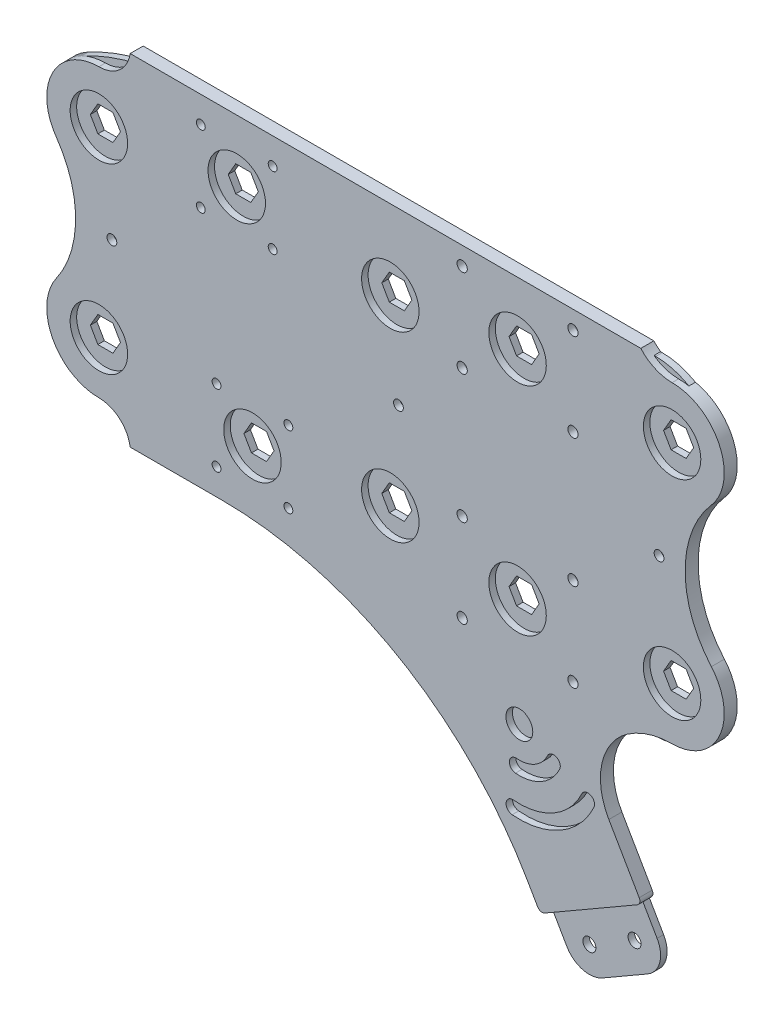
from build123d import *

# Parameters (mm, degrees)
SKETCH1_R           = 2.159
SKETCH1_R_2         = 2.5
SKETCH1_R_3         = 3.175
BOSS_EXTRUDE3_DEPTH = 3.175
SKETCH4_R           = 14
SKETCH4_R_2         = 2.38125
SKETCH4_R_3         = 2.159
SKETCH4_R_4         = 2.5
SKETCH4_R_5         = 6.54812
BOSS_EXTRUDE4_DEPTH = 6.35
FILLET1_R           = 2.54


with BuildPart() as part:
    # Sketch1 → Boss-Extrude3 (new body)
    with BuildSketch(Plane.XY):
        with BuildLine():
            Line((113.584291992, 80.1116), (113.584291992, 54.7116))
            Line((113.584291992, 54.7116), (88.184291992, 54.7116))
            Line((88.184291992, 54.7116), (88.184291992, 80.1116))
            Line((88.184291992, 80.1116), (39.822691992, 80.1116))
            ThreePointArc((39.822691992, 80.1116), (12.922826287, 76.701489547), (-12.275183404, 66.686903391))
            ThreePointArc((-12.275183404, 66.686903391), (-25.397490808, 44.807016355), (-12.895384615, 22.566923077))
            ThreePointArc((-12.895384615, 22.566923077), (0, 0), (-12.895384615, -22.566923077))
            ThreePointArc((-12.895384615, -22.566923077), (-25.397490808, -44.807016355), (-12.275183404, -66.686903391))
            ThreePointArc((-12.275183404, -66.686903391), (7.438885646, -75.132543085), (28.434721687, -79.50841069))
            Line((28.434721687, -79.50841069), (28.434721687, -54.7116))
            Line((28.434721687, -54.7116), (53.834721687, -54.7116))
            Line((53.834721687, -54.7116), (53.834721687, -80.1116))
            Line((53.834721687, -80.1116), (131.769044239, -80.1116))
            ThreePointArc((131.769044239, -80.1116), (157.169044239, -86.917509488), (175.763134751, -105.5116))
            Line((175.763134751, -105.5116), (224.861657379, -190.552735768))
            ThreePointArc((224.861657379, -190.552735768), (232.573178135, -196.469993762), (242.210180007, -195.201258396))
            Line((242.210180007, -195.201258396), (264.207225263, -182.501258396))
            ThreePointArc((264.207225263, -182.501258396), (270.124483257, -174.789737641), (268.855747892, -165.152735768))
            Line((268.855747892, -165.152735768), (230.755747892, -99.1616))
            ThreePointArc((230.755747892, -99.1616), (230.755747892, -86.4616), (241.75427052, -80.1116))
            Line((241.75427052, -80.1116), (268.191665038, -80.1116))
            ThreePointArc((268.191665038, -80.1116), (298.862941972, -56.567407166), (284.04568608, -20.853191889))
            ThreePointArc((284.04568608, -20.853191889), (271.99548317, 0), (284.04568608, 20.853191889))
            ThreePointArc((284.04568608, 20.853191889), (298.862941972, 56.567407166), (268.191665038, 80.1116))
            Line((268.191665038, 80.1116), (113.584291992, 80.1116))
        make_face()
        with Locations((49.675972812, 35.25328082)):
            Circle(SKETCH1_R, mode=Mode.SUBTRACT)
        with Locations((49.675972812, 70.25831918)):
            Circle(SKETCH1_R, mode=Mode.SUBTRACT)
        with Locations((84.681011172, 35.25328082)):
            Circle(SKETCH1_R, mode=Mode.SUBTRACT)
        with Locations((84.681011172, 70.25831918)):
            Circle(SKETCH1_R, mode=Mode.SUBTRACT)
        with Locations((231.027831589, 74.2058)):
            Circle(SKETCH1_R_2, mode=Mode.SUBTRACT)
        with Locations((231.027831589, 31.3058)):
            Circle(SKETCH1_R_2, mode=Mode.SUBTRACT)
        with Locations((216.810180007, -151.207167884)):
            Circle(SKETCH1_R_3, mode=Mode.SUBTRACT)
        with Locations((235.860180007, -184.202735768)):
            Circle(SKETCH1_R_3, mode=Mode.SUBTRACT)
        with Locations((257.857225263, -171.502735768)):
            Circle(SKETCH1_R_3, mode=Mode.SUBTRACT)
        with Locations((238.807225263, -138.507167884)):
            Circle(SKETCH1_R_3, mode=Mode.SUBTRACT)
        with Locations((197.760180007, -118.2116)):
            Circle(SKETCH1_R_3, mode=Mode.SUBTRACT)
        with Locations((177.027831589, -74.2058)):
            Circle(SKETCH1_R_2, mode=Mode.SUBTRACT)
        with Locations((219.757225263, -105.5116)):
            Circle(SKETCH1_R_3, mode=Mode.SUBTRACT)
        with Locations((231.027831589, -74.2058)):
            Circle(SKETCH1_R_2, mode=Mode.SUBTRACT)
        with Locations((177.027831589, -31.3058)):
            Circle(SKETCH1_R_2, mode=Mode.SUBTRACT)
        with Locations((231.027831589, -31.3058)):
            Circle(SKETCH1_R_2, mode=Mode.SUBTRACT)
        with Locations((177.027831589, 31.3058)):
            Circle(SKETCH1_R_2, mode=Mode.SUBTRACT)
        with Locations((177.027831589, 74.2058)):
            Circle(SKETCH1_R_2, mode=Mode.SUBTRACT)
        with Locations((92.343040867, -35.25328082)):
            Circle(SKETCH1_R, mode=Mode.SUBTRACT)
        with Locations((57.338002507, -35.25328082)):
            Circle(SKETCH1_R, mode=Mode.SUBTRACT)
        with Locations((92.343040867, -70.25831918)):
            Circle(SKETCH1_R, mode=Mode.SUBTRACT)
        with Locations((57.338002507, -70.25831918)):
            Circle(SKETCH1_R, mode=Mode.SUBTRACT)
        Polygon((74.510840411, 52.7558), (70.844666202, 46.4058), (63.512317783, 46.4058), (59.846143574, 52.7558), (63.512317783, 59.1058), (70.844666202, 59.1058), align=None, mode=Mode.SUBTRACT)
        Polygon((207.694005798, 59.1058), (211.360180007, 52.7558), (207.694005798, 46.4058), (200.361657379, 46.4058), (196.69548317, 52.7558), (200.361657379, 59.1058), align=None, mode=Mode.SUBTRACT)
        Polygon((282.994005798, 57.15), (286.660180007, 50.8), (282.994005798, 44.45), (275.661657379, 44.45), (271.99548317, 50.8), (275.661657379, 57.15), align=None, mode=Mode.SUBTRACT)
        Polygon((286.660180007, -50.8), (282.994005798, -57.15), (275.661657379, -57.15), (271.99548317, -50.8), (275.661657379, -44.45), (282.994005798, -44.45), align=None, mode=Mode.SUBTRACT)
        Polygon((207.694005798, -46.4058), (211.360180007, -52.7558), (207.694005798, -59.1058), (200.361657379, -59.1058), (196.69548317, -52.7558), (200.361657379, -46.4058), align=None, mode=Mode.SUBTRACT)
        Polygon((78.506695896, -46.4058), (82.172870106, -52.7558), (78.506695896, -59.1058), (71.174347477, -59.1058), (67.508173268, -52.7558), (71.174347477, -46.4058), align=None, mode=Mode.SUBTRACT)
        Polygon((3.666174209, 50.8), (7.332348419, 44.45), (3.666174209, 38.1), (-3.666174209, 38.1), (-7.332348419, 44.45), (-3.666174209, 50.8), align=None, mode=Mode.SUBTRACT)
        Polygon((7.332348419, -44.45), (3.666174209, -50.8), (-3.666174209, -50.8), (-7.332348419, -44.45), (-3.666174209, -38.1), (3.666174209, -38.1), align=None, mode=Mode.SUBTRACT)
        Polygon((145.685187889, 50.8), (149.351362098, 44.45), (145.685187889, 38.1), (138.35283947, 38.1), (134.68666526, 44.45), (138.35283947, 50.8), align=None, mode=Mode.SUBTRACT)
        Polygon((149.351362098, -44.45), (145.685187889, -50.8), (138.35283947, -50.8), (134.68666526, -44.45), (138.35283947, -38.1), (145.685187889, -38.1), align=None, mode=Mode.SUBTRACT)
    extrude(amount=BOSS_EXTRUDE3_DEPTH)


with BuildPart() as body_2:
    # Sketch4 → Boss-Extrude4 (new body)
    with BuildSketch(Plane.XY):
        with BuildLine():
            Line((15.24, 83.0558), (264.087831589, 83.0558))
            ThreePointArc((264.087831589, 83.0558), (270.972300582, 77.992862142), (279.327831589, 76.2))
            ThreePointArc((279.327831589, 76.2), (302.451140116, 61.310594785), (298.46481789, 34.098630137))
            ThreePointArc((298.46481789, 34.098630137), (285.677831589, 0), (298.46481789, -34.098630137))
            ThreePointArc((298.46481789, -34.098630137), (302.451140116, -61.310594785), (279.327831589, -76.2))
            ThreePointArc((279.327831589, -76.2), (267.899665069, -77.954339874), (257.523933626, -83.0558))
            ThreePointArc((257.523933626, -83.0558), (245.131598289, -101.554723393), (248.51009846, -123.56303724))
            Line((248.51009846, -123.56303724), (264.565147031, -151.371197082))
            Line((264.565147031, -151.371197082), (215.071795204, -179.946197082))
            Line((215.071795204, -179.946197082), (208.721795204, -168.947674454))
            ThreePointArc((208.721795204, -168.947674454), (145.844579146, -106.070458396), (59.952704692, -83.0558))
            Line((59.952704692, -83.0558), (15.24, -83.0558))
            ThreePointArc((15.24, -83.0558), (10.082791697, -73.610743867), (0, -69.85))
            ThreePointArc((0, -69.85), (-22.542714402, -56.154103015), (-20.774980442, -29.83630137))
            ThreePointArc((-20.774980442, -29.83630137), (-11.332232176, 0), (-20.774980442, 29.83630137))
            ThreePointArc((-20.774980442, 29.83630137), (-22.542714402, 56.154103015), (0, 69.85))
            ThreePointArc((0, 69.85), (10.082791697, 73.610743867), (15.24, 83.0558))
        make_face()
        with Locations((0, 44.45)):
            Circle(SKETCH4_R, mode=Mode.SUBTRACT)
        with Locations((142.019013679, 44.45)):
            Circle(SKETCH4_R, mode=Mode.SUBTRACT)
        with Locations((279.327831589, 50.8)):
            Circle(SKETCH4_R, mode=Mode.SUBTRACT)
        with Locations((279.327831589, -50.8)):
            Circle(SKETCH4_R, mode=Mode.SUBTRACT)
        with Locations((142.019013679, -44.45)):
            Circle(SKETCH4_R, mode=Mode.SUBTRACT)
        with Locations((0, -44.45)):
            Circle(SKETCH4_R, mode=Mode.SUBTRACT)
        with Locations((67.178491992, 52.7558)):
            Circle(SKETCH4_R, mode=Mode.SUBTRACT)
        with Locations((204.027831589, 52.7558)):
            Circle(SKETCH4_R, mode=Mode.SUBTRACT)
        with Locations((204.027831589, -52.7558)):
            Circle(SKETCH4_R, mode=Mode.SUBTRACT)
        with Locations((74.840521687, -52.7558)):
            Circle(SKETCH4_R, mode=Mode.SUBTRACT)
        with Locations((6.35, 0)):
            Circle(SKETCH4_R_2, mode=Mode.SUBTRACT)
        with Locations((272.977831589, 0)):
            Circle(SKETCH4_R_2, mode=Mode.SUBTRACT)
        with Locations((145.977831589, 0)):
            Circle(SKETCH4_R_2, mode=Mode.SUBTRACT)
        with Locations((92.343040867, -70.25831918)):
            Circle(SKETCH4_R_3, mode=Mode.SUBTRACT)
        with Locations((57.338002507, -70.25831918)):
            Circle(SKETCH4_R_3, mode=Mode.SUBTRACT)
        with Locations((57.338002507, -35.25328082)):
            Circle(SKETCH4_R_3, mode=Mode.SUBTRACT)
        with Locations((92.343040867, -35.25328082)):
            Circle(SKETCH4_R_3, mode=Mode.SUBTRACT)
        with Locations((177.027831589, -74.2058)):
            Circle(SKETCH4_R_4, mode=Mode.SUBTRACT)
        with Locations((231.027831589, -74.2058)):
            Circle(SKETCH4_R_4, mode=Mode.SUBTRACT)
        with Locations((231.027831589, -31.3058)):
            Circle(SKETCH4_R_4, mode=Mode.SUBTRACT)
        with Locations((177.027831589, -31.3058)):
            Circle(SKETCH4_R_4, mode=Mode.SUBTRACT)
        with Locations((231.027831589, 31.3058)):
            Circle(SKETCH4_R_4, mode=Mode.SUBTRACT)
        with Locations((231.027831589, 74.2058)):
            Circle(SKETCH4_R_4, mode=Mode.SUBTRACT)
        with Locations((177.027831589, 31.3058)):
            Circle(SKETCH4_R_4, mode=Mode.SUBTRACT)
        with Locations((177.027831589, 74.2058)):
            Circle(SKETCH4_R_4, mode=Mode.SUBTRACT)
        with Locations((49.675972812, 35.25328082)):
            Circle(SKETCH4_R_3, mode=Mode.SUBTRACT)
        with Locations((84.681011172, 35.25328082)):
            Circle(SKETCH4_R_3, mode=Mode.SUBTRACT)
        with Locations((84.681011172, 70.25831918)):
            Circle(SKETCH4_R_3, mode=Mode.SUBTRACT)
        with Locations((49.675972812, 70.25831918)):
            Circle(SKETCH4_R_3, mode=Mode.SUBTRACT)
        with Locations((204.893471118, -105.166822628)):
            Circle(SKETCH4_R_5, mode=Mode.SUBTRACT)
        with BuildLine():
            ThreePointArc((201.399057483, -145.108153234), (224.940421118, -139.889158565), (241.2308849, -122.111236952))
            ThreePointArc((241.2308849, -122.111236952), (239.652170659, -117.773755222), (235.314688928, -119.352469463))
            ThreePointArc((235.314688928, -119.352469463), (221.676521118, -134.235917934), (201.967992741, -138.605193484))
            ThreePointArc((201.967992741, -138.605193484), (198.432045237, -141.57220573), (201.399057483, -145.108153234))
        make_face(mode=Mode.SUBTRACT)
        with BuildLine():
            ThreePointArc((203.004030486, -126.763227869), (215.732921118, -123.941300754), (224.541227002, -114.328721663))
            ThreePointArc((224.541227002, -114.328721663), (222.96251276, -109.991239932), (218.62503103, -111.569954174))
            ThreePointArc((218.62503103, -111.569954174), (212.469021118, -118.288060123), (203.572965744, -120.260268118))
            ThreePointArc((203.572965744, -120.260268118), (200.03701824, -123.227280365), (203.004030486, -126.763227869))
        make_face(mode=Mode.SUBTRACT)
    extrude(amount=BOSS_EXTRUDE4_DEPTH)

    # Fillet1
    fillet1_edges = [body_2.edges().sort_by_distance(p)[0] for p in [
        (264.565147031, -151.371197082, 3.175),
        (215.071795204, -179.946197082, 3.175),
    ]]
    fillet(fillet1_edges, radius=FILLET1_R)


solid = Compound([part.part, body_2.part])
